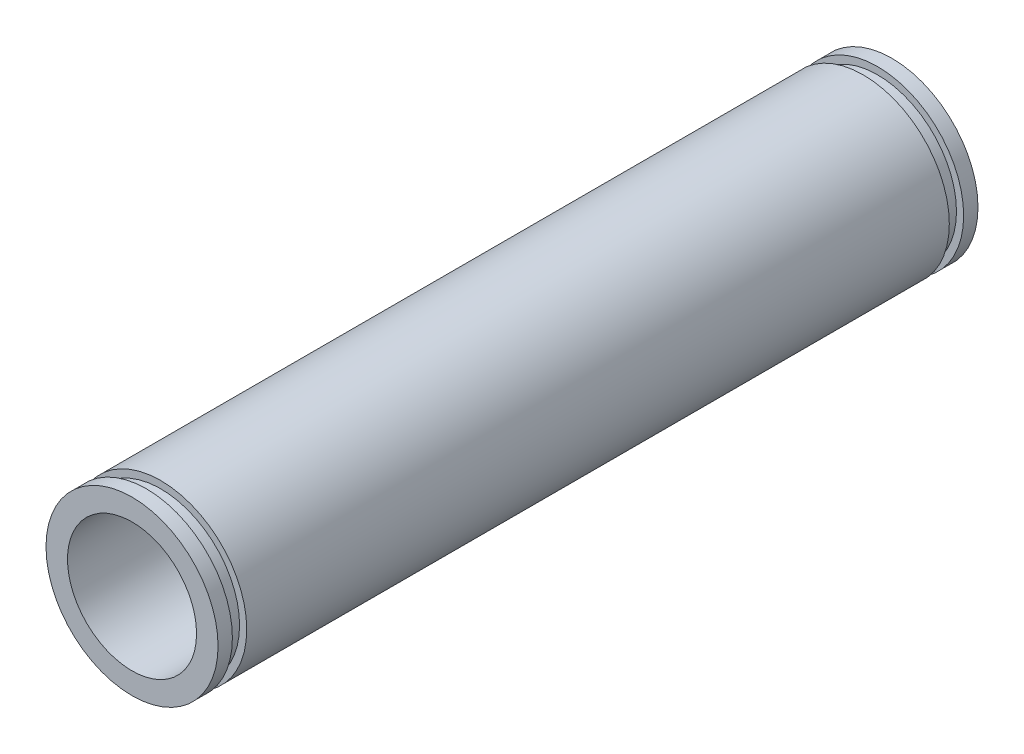
from build123d import *

# Parameters (mm, degrees)
SKETCH_1_R          = 6
SKETCH_1_R_2        = 4.5
EXTRUDE_1_DEPTH     = 26.5
CUT_EXTRUDE_START   = -1
SKETCH_2_R          = 6
SKETCH_2_R_2        = 5.5
CUT_EXTRUDE_1_DEPTH = 1


with BuildPart() as part:
    # Эскиз1 → Бобышка-Вытянуть1 (new body, symmetric)
    with BuildSketch(Plane.XY):
        Circle(SKETCH_1_R)
        Circle(SKETCH_1_R_2, mode=Mode.SUBTRACT)
    extrude(amount=EXTRUDE_1_DEPTH, both=True)

    # Эскиз2 → Вырез-Вытянуть1 (cut)
    with BuildSketch(Plane.XY.offset(26.5).offset(CUT_EXTRUDE_START)):
        Circle(SKETCH_2_R)
        Circle(SKETCH_2_R_2, mode=Mode.SUBTRACT)
    cut_extrude_1 = extrude(amount=-CUT_EXTRUDE_1_DEPTH, mode=Mode.SUBTRACT)

    # Зеркальное отражение1: Вырез-Вытянуть1 across plane
    add(cut_extrude_1.mirror(Plane.XY), mode=Mode.SUBTRACT)


solid = part.part
